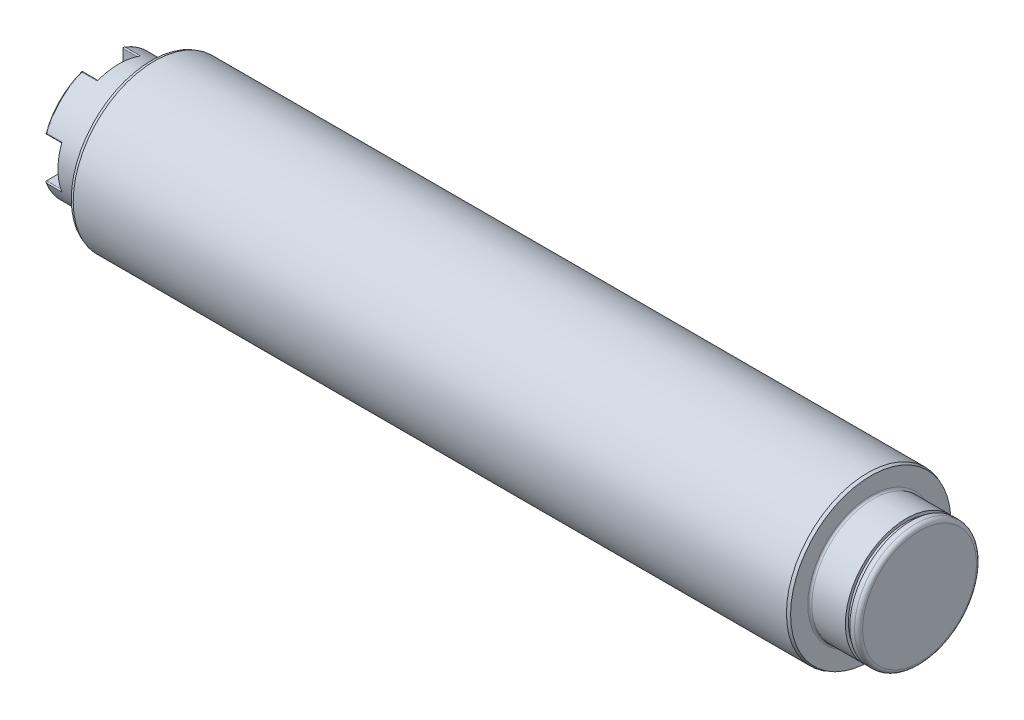
from build123d import *

# Parameters (mm, degrees)
R1_RUNDING_R     = 1
AFFR_SNING_DEPTH = 8
R0_5_RUNDINGER_R = 0.5


with BuildPart() as part:
    # Sketch1 → Base-Revolve (revolve)
    with BuildSketch(Plane.XY):
        with BuildLine():
            Line((-201, 20), (-201, 30))
            Line((-201, 30), (-177, 30))
            Line((-177, 30), (-177, 39.454044649))
            Line((-177, 39.454044649), (-175.5, 40))
            Line((-175.5, 40), (175.5, 40))
            Line((175.5, 40), (177, 39.454044649))
            Line((177, 39.454044649), (177, 30))
            Line((177, 30), (194.5, 30))
            Line((194.5, 30), (194.5, 28.5))
            Line((194.5, 28.5), (196.65, 28.5))
            Line((196.65, 28.5), (196.65, 30))
            Line((196.65, 30), (199, 30))
            ThreePointArc((199, 30), (200.414213562, 29.414213562), (201, 28))
            Line((201, 28), (201, 0))
            Line((201, 0), (-146.793975667, 0))
            Line((-146.793975667, 0), (-151, 7))
            Line((-151, 7), (-182.098709071, 7))
            Line((-182.098709071, 7), (-183, 8.5))
            Line((-183, 8.5), (-193, 8.5))
            Line((-193, 8.5), (-193, 20))
            Line((-193, 20), (-201, 20))
        make_face()
    revolve(axis=Axis((-283, 0, 0), (1, 0, 0)))

    # R1 runding
    r1_runding_edges = [part.edges().sort_by_distance(p)[0] for p in [
        (-177, -30, 0),
        (177, -30, 0),
    ]]
    fillet(r1_runding_edges, radius=R1_RUNDING_R)

    # Sketch3 → Affræsning (cut)
    with BuildSketch(Plane.ZY.offset(201)):
        with BuildLine():
            Line((10, 28.284271247), (10, 17.320508076))
            ThreePointArc((10, 17.320508076), (0, 20), (-10, 17.320508076))
            Line((-10, 17.320508076), (-10, 28.284271247))
            ThreePointArc((-10, 28.284271247), (0, 30), (10, 28.284271247))
        make_face()
        with BuildLine():
            Line((17.320508076, 10), (28.284271247, 10))
            ThreePointArc((28.284271247, 10), (30, 0), (28.284271247, -10))
            Line((28.284271247, -10), (17.320508076, -10))
            ThreePointArc((17.320508076, -10), (20, 0), (17.320508076, 10))
        make_face()
        with BuildLine():
            Line((-17.320508076, -10), (-28.284271247, -10))
            ThreePointArc((-28.284271247, -10), (-30, 0), (-28.284271247, 10))
            Line((-28.284271247, 10), (-17.320508076, 10))
            ThreePointArc((-17.320508076, 10), (-20, 0), (-17.320508076, -10))
        make_face()
        with BuildLine():
            Line((-10, -28.284271247), (-10, -17.320508076))
            ThreePointArc((-10, -17.320508076), (0, -20), (10, -17.320508076))
            Line((10, -17.320508076), (10, -28.284271247))
            ThreePointArc((10, -28.284271247), (0, -30), (-10, -28.284271247))
        make_face()
    extrude(amount=-AFFR_SNING_DEPTH, mode=Mode.SUBTRACT)

    # R0.5 rundinger
    r0_5_rundinger_edges = [part.edges().sort_by_distance(p)[0] for p in [
        (-201, 14.142135624, -14.142135624),
        (-201, 21.213203436, -21.213203436),
        (-197, 28.284271247, -10),
        (-197, 28.284271247, 10),
        (-197, 17.320508076, 10),
        (-197, 17.320508076, -10),
        (-201, 14.142135624, 14.142135624),
        (-201, 21.213203436, 21.213203436),
        (-197, -10, 17.320508076),
        (-197, 10, 17.320508076),
        (-197, 10, 28.284271247),
        (-197, -10, 28.284271247),
        (-201, -14.142135624, -14.142135624),
        (-201, -21.213203436, -21.213203436),
        (-197, 10, -17.320508076),
        (-197, -10, -17.320508076),
        (-197, -10, -28.284271247),
        (-197, 10, -28.284271247),
        (-201, -21.213203436, 21.213203436),
        (-201, -14.142135624, 14.142135624),
        (-197, -28.284271247, 10),
        (-197, -28.284271247, -10),
        (-197, -17.320508076, -10),
        (-197, -17.320508076, 10),
    ]]
    fillet(r0_5_rundinger_edges, radius=R0_5_RUNDINGER_R)


solid = part.part
